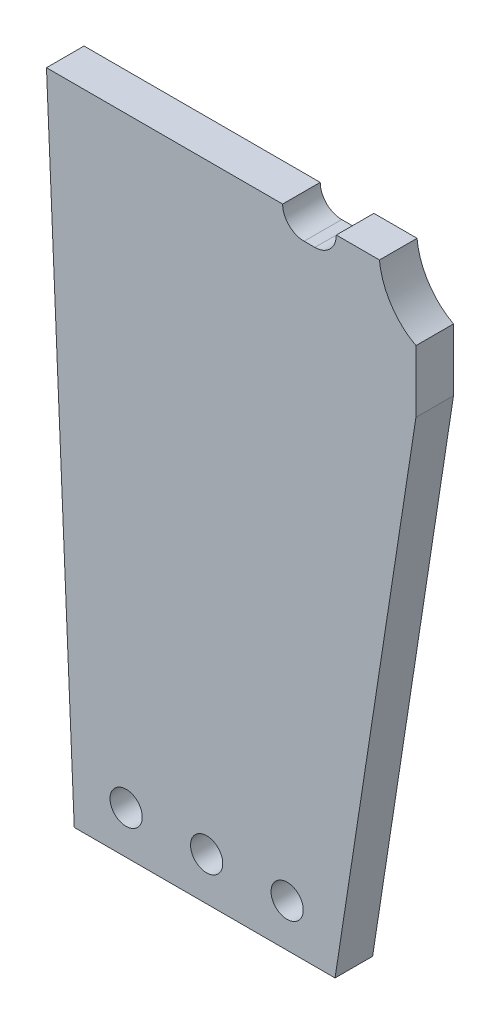
from build123d import *

# Parameters (mm, degrees)
SKETCH1_R           = 4.5
BOSS_EXTRUDE1_DEPTH = 7
SKETCH2_W           = 402.918493315
SKETCH2_H           = 212.645905023
CUT_EXTRUDE1_DEPTH  = 30
SKETCH3_R           = 3
CUT_EXTRUDE2_DEPTH  = 8.0000001


with BuildPart() as part:
    # Sketch1 → Boss-Extrude1 (new body)
    with BuildSketch(Plane.XY):
        with BuildLine():
            Line((22, -50), (-22, -50))
            Line((-22, -50), (-11, -305))
            ThreePointArc((-11, -305), (0, -315.535719965), (11, -305))
            Line((11, -305), (46.838884711, -72))
            Line((46.838884711, -72), (46.838884711, -60.421650598))
            add(Edge.make_bspline(
                [(46.838884711, -60.421650596), (43.068657692, -58.44092391), (40.423050609, -54.296947681), (40.046232129, -50)],
                knots=[0, 0, 0, 0, 0.425250978, 0.425250978, 0.425250978, 0.425250978], degree=3))
            Line((40.046232129, -50), (32, -50))
            ThreePointArc((32, -50), (30.828427125, -52.828427125), (28, -54))
            Line((28, -54), (26, -54))
            ThreePointArc((26, -54), (23.171572875, -52.828427125), (22, -50))
        make_face()
        with Locations((0, -305)):
            Circle(SKETCH1_R, mode=Mode.SUBTRACT)
    extrude(amount=BOSS_EXTRUDE1_DEPTH)

    # Sketch2 → Cut-Extrude1 (cut)
    with BuildSketch(Plane.XY.offset(7)):
        with Locations((44.983042226, -276.322952512)):
            Rectangle(SKETCH2_W, SKETCH2_H)
    extrude(amount=-CUT_EXTRUDE1_DEPTH, mode=Mode.SUBTRACT)

    # Sketch3 → Cut-Extrude2 (cut, through all)
    with BuildSketch(Plane.XY.offset(7)):
        with Locations((-7.159327661, -162)):
            Circle(SKETCH3_R)
        with Locations((7.840672339, -162)):
            Circle(SKETCH3_R)
        with Locations((22.840672339, -162)):
            Circle(SKETCH3_R)
    extrude(amount=-CUT_EXTRUDE2_DEPTH, mode=Mode.SUBTRACT)


solid = part.part
